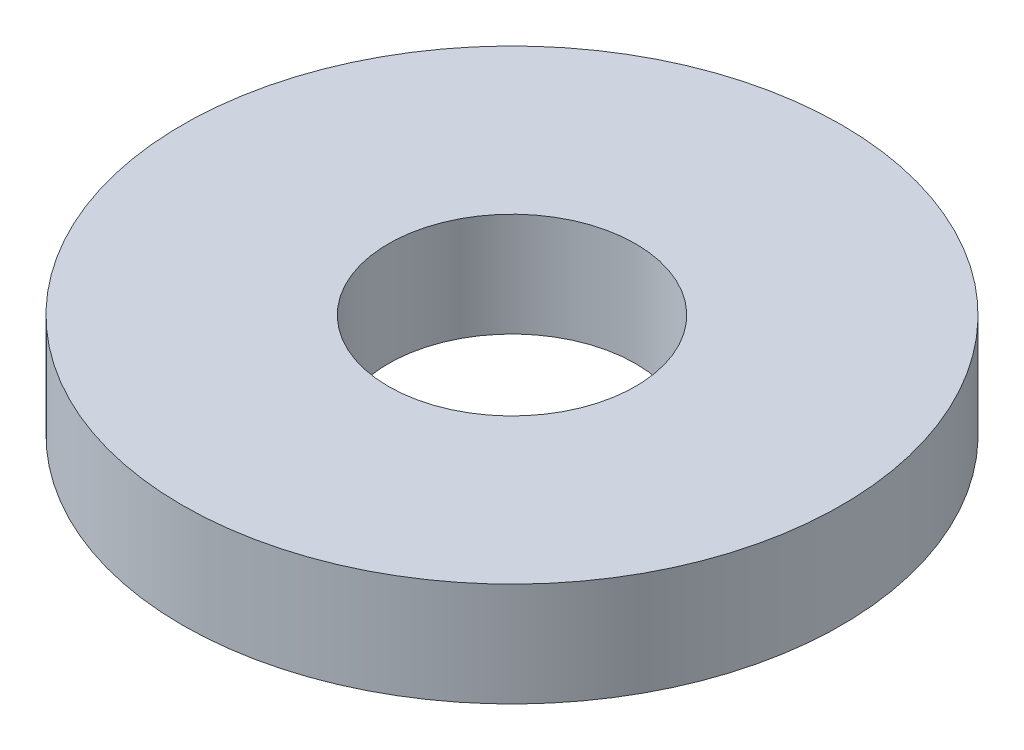
from build123d import *

# Parameters (mm, degrees)
SKETCH1_R           = 12.7
SKETCH1_R_2         = 4.7625
BOSS_EXTRUDE1_DEPTH = 4


with BuildPart() as part:
    # Sketch1 → Boss-Extrude1 (new body)
    with BuildSketch(Plane(origin=(0, 0, 0), x_dir=(1, 0, 0), z_dir=(0, 1, 0))):
        Circle(SKETCH1_R)
        Circle(SKETCH1_R_2, mode=Mode.SUBTRACT)
    extrude(amount=BOSS_EXTRUDE1_DEPTH)


solid = part.part
